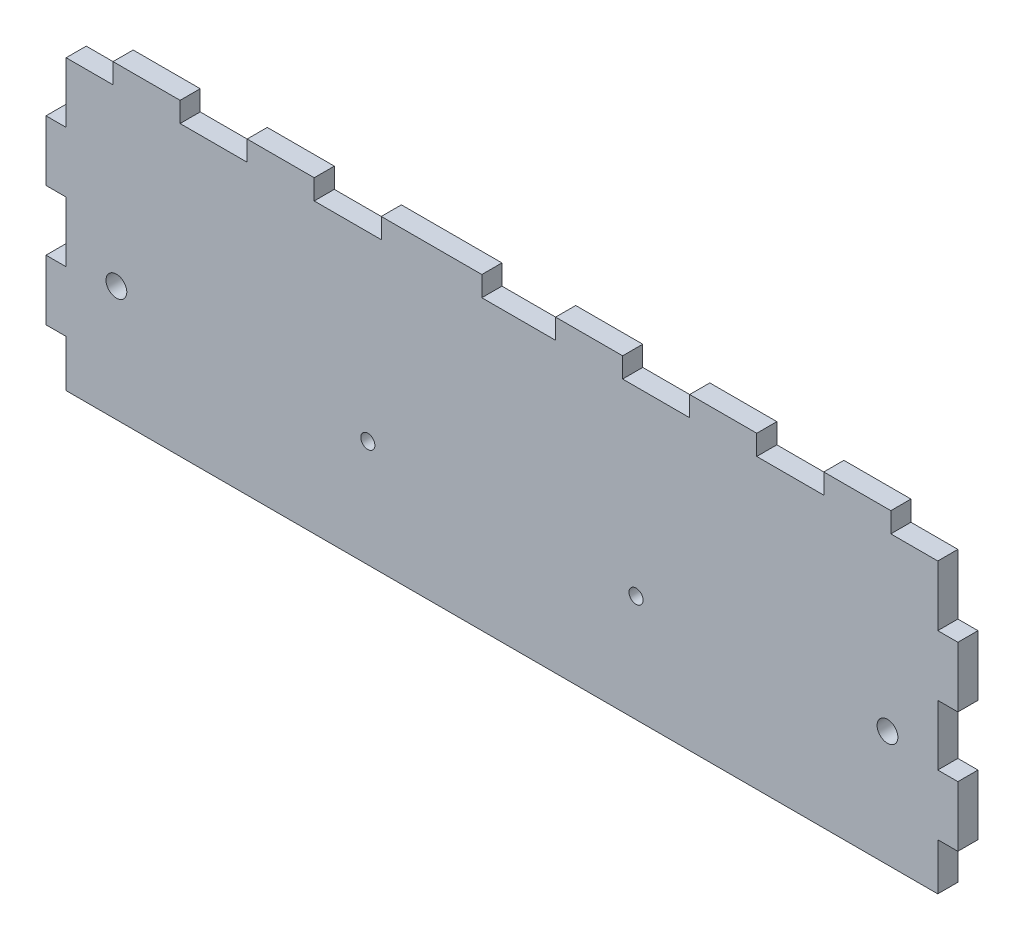
from build123d import *

# Parameters (mm, degrees)
SKETCH1_W           = 136
SKETCH1_H           = 46
SKETCH1_R           = 1.05
SKETCH1_R_2         = 1.55
BOSS_EXTRUDE1_DEPTH = 3
CUT_EXTRUDE1_REACH  = 5
SKETCH2_W           = 11
SKETCH2_H           = 3
SKETCH2_W_2         = 10
SKETCH2_W_3         = 3
SKETCH2_H_2         = 9
SKETCH2_H_3         = 7


with BuildPart() as part:
    # Sketch1 → Boss-Extrude1 (new body)
    with BuildSketch(Plane.XY):
        with Locations((-68, 23)):
            Rectangle(SKETCH1_W, SKETCH1_H)
        with Locations((-88, 15.95)):
            Circle(SKETCH1_R, mode=Mode.SUBTRACT)
        with Locations((-125.5, 17.25)):
            Circle(SKETCH1_R_2, mode=Mode.SUBTRACT)
        with Locations((-48, 15.95)):
            Circle(SKETCH1_R, mode=Mode.SUBTRACT)
        with Locations((-10.5, 17.25)):
            Circle(SKETCH1_R_2, mode=Mode.SUBTRACT)
    extrude(amount=BOSS_EXTRUDE1_DEPTH)

    # Sketch2 → Cut-Extrude1 (cut, up to next)
    with BuildSketch(Plane.XY.offset(3), mode=Mode.PRIVATE) as cut_extrude1_sk1:
        with Locations((-65.5, 44.5)):
            Rectangle(SKETCH2_W, SKETCH2_H)
    cut_extrude1_tool1 = extrude(cut_extrude1_sk1.sketch, amount=-CUT_EXTRUDE1_REACH, mode=Mode.PRIVATE) & part.part
    add(cut_extrude1_tool1.solids().sort_by_distance((-65.5, 44.5, 3))[0], mode=Mode.SUBTRACT)
    # Sketch2 → Cut-Extrude1 (cut, up to next)
    with BuildSketch(Plane.XY.offset(3), mode=Mode.PRIVATE) as cut_extrude1_sk2:
        with Locations((-91, 44.5)):
            Rectangle(SKETCH2_W_2, SKETCH2_H)
    cut_extrude1_tool2 = extrude(cut_extrude1_sk2.sketch, amount=-CUT_EXTRUDE1_REACH, mode=Mode.PRIVATE) & part.part
    add(cut_extrude1_tool2.solids().sort_by_distance((-91, 44.5, 3))[0], mode=Mode.SUBTRACT)
    # Sketch2 → Cut-Extrude1 (cut, up to next)
    with BuildSketch(Plane.XY.offset(3), mode=Mode.PRIVATE) as cut_extrude1_sk3:
        with Locations((-111, 44.5)):
            Rectangle(SKETCH2_W_2, SKETCH2_H)
    cut_extrude1_tool3 = extrude(cut_extrude1_sk3.sketch, amount=-CUT_EXTRUDE1_REACH, mode=Mode.PRIVATE) & part.part
    add(cut_extrude1_tool3.solids().sort_by_distance((-111, 44.5, 3))[0], mode=Mode.SUBTRACT)
    # Sketch2 → Cut-Extrude1 (cut, up to next)
    with BuildSketch(Plane.XY.offset(3), mode=Mode.PRIVATE) as cut_extrude1_sk4:
        Polygon((-136, 43), (-133, 43), (-126, 43), (-126, 46), (-136, 46), align=None)
    cut_extrude1_tool4 = extrude(cut_extrude1_sk4.sketch, amount=-CUT_EXTRUDE1_REACH, mode=Mode.PRIVATE) & part.part
    add(cut_extrude1_tool4.solids().sort_by_distance((-131, 44.5, 3))[0], mode=Mode.SUBTRACT)
    # Sketch2 → Cut-Extrude1 (cut, up to next)
    with BuildSketch(Plane.XY.offset(3), mode=Mode.PRIVATE) as cut_extrude1_sk5:
        with Locations((-134.5, 38.5)):
            Rectangle(SKETCH2_W_3, SKETCH2_H_2)
    cut_extrude1_tool5 = extrude(cut_extrude1_sk5.sketch, amount=-CUT_EXTRUDE1_REACH, mode=Mode.PRIVATE) & part.part
    add(cut_extrude1_tool5.solids().sort_by_distance((-134.5, 38.5, 3))[0], mode=Mode.SUBTRACT)
    # Sketch2 → Cut-Extrude1 (cut, up to next)
    with BuildSketch(Plane.XY.offset(3), mode=Mode.PRIVATE) as cut_extrude1_sk6:
        with Locations((-134.5, 20.5)):
            Rectangle(SKETCH2_W_3, SKETCH2_H_2)
    cut_extrude1_tool6 = extrude(cut_extrude1_sk6.sketch, amount=-CUT_EXTRUDE1_REACH, mode=Mode.PRIVATE) & part.part
    add(cut_extrude1_tool6.solids().sort_by_distance((-134.5, 20.5, 3))[0], mode=Mode.SUBTRACT)
    # Sketch2 → Cut-Extrude1 (cut, up to next)
    with BuildSketch(Plane.XY.offset(3), mode=Mode.PRIVATE) as cut_extrude1_sk7:
        with Locations((-134.5, 3.5)):
            Rectangle(SKETCH2_W_3, SKETCH2_H_3)
    cut_extrude1_tool7 = extrude(cut_extrude1_sk7.sketch, amount=-CUT_EXTRUDE1_REACH, mode=Mode.PRIVATE) & part.part
    add(cut_extrude1_tool7.solids().sort_by_distance((-134.5, 3.5, 3))[0], mode=Mode.SUBTRACT)
    # Sketch2 → Cut-Extrude1 (cut, up to next)
    with BuildSketch(Plane.XY.offset(3), mode=Mode.PRIVATE) as cut_extrude1_sk8:
        with Locations((-1.5, 3.5)):
            Rectangle(SKETCH2_W_3, SKETCH2_H_3)
    cut_extrude1_tool8 = extrude(cut_extrude1_sk8.sketch, amount=-CUT_EXTRUDE1_REACH, mode=Mode.PRIVATE) & part.part
    add(cut_extrude1_tool8.solids().sort_by_distance((-1.5, 3.5, 3))[0], mode=Mode.SUBTRACT)
    # Sketch2 → Cut-Extrude1 (cut, up to next)
    with BuildSketch(Plane.XY.offset(3), mode=Mode.PRIVATE) as cut_extrude1_sk9:
        with Locations((-1.5, 20.5)):
            Rectangle(SKETCH2_W_3, SKETCH2_H_2)
    cut_extrude1_tool9 = extrude(cut_extrude1_sk9.sketch, amount=-CUT_EXTRUDE1_REACH, mode=Mode.PRIVATE) & part.part
    add(cut_extrude1_tool9.solids().sort_by_distance((-1.5, 20.5, 3))[0], mode=Mode.SUBTRACT)
    # Sketch2 → Cut-Extrude1 (cut, up to next)
    with BuildSketch(Plane.XY.offset(3), mode=Mode.PRIVATE) as cut_extrude1_sk10:
        with Locations((-1.5, 38.5)):
            Rectangle(SKETCH2_W_3, SKETCH2_H_2)
    cut_extrude1_tool10 = extrude(cut_extrude1_sk10.sketch, amount=-CUT_EXTRUDE1_REACH, mode=Mode.PRIVATE) & part.part
    add(cut_extrude1_tool10.solids().sort_by_distance((-1.5, 38.5, 3))[0], mode=Mode.SUBTRACT)
    # Sketch2 → Cut-Extrude1 (cut, up to next)
    with BuildSketch(Plane.XY.offset(3), mode=Mode.PRIVATE) as cut_extrude1_sk11:
        Polygon((0, 46), (-10, 46), (-10, 43), (-3, 43), (0, 43), align=None)
    cut_extrude1_tool11 = extrude(cut_extrude1_sk11.sketch, amount=-CUT_EXTRUDE1_REACH, mode=Mode.PRIVATE) & part.part
    add(cut_extrude1_tool11.solids().sort_by_distance((-5, 44.5, 3))[0], mode=Mode.SUBTRACT)
    # Sketch2 → Cut-Extrude1 (cut, up to next)
    with BuildSketch(Plane.XY.offset(3), mode=Mode.PRIVATE) as cut_extrude1_sk12:
        with Locations((-25, 44.5)):
            Rectangle(SKETCH2_W_2, SKETCH2_H)
    cut_extrude1_tool12 = extrude(cut_extrude1_sk12.sketch, amount=-CUT_EXTRUDE1_REACH, mode=Mode.PRIVATE) & part.part
    add(cut_extrude1_tool12.solids().sort_by_distance((-25, 44.5, 3))[0], mode=Mode.SUBTRACT)
    # Sketch2 → Cut-Extrude1 (cut, up to next)
    with BuildSketch(Plane.XY.offset(3), mode=Mode.PRIVATE) as cut_extrude1_sk13:
        with Locations((-45, 44.5)):
            Rectangle(SKETCH2_W_2, SKETCH2_H)
    cut_extrude1_tool13 = extrude(cut_extrude1_sk13.sketch, amount=-CUT_EXTRUDE1_REACH, mode=Mode.PRIVATE) & part.part
    add(cut_extrude1_tool13.solids().sort_by_distance((-45, 44.5, 3))[0], mode=Mode.SUBTRACT)


solid = part.part
